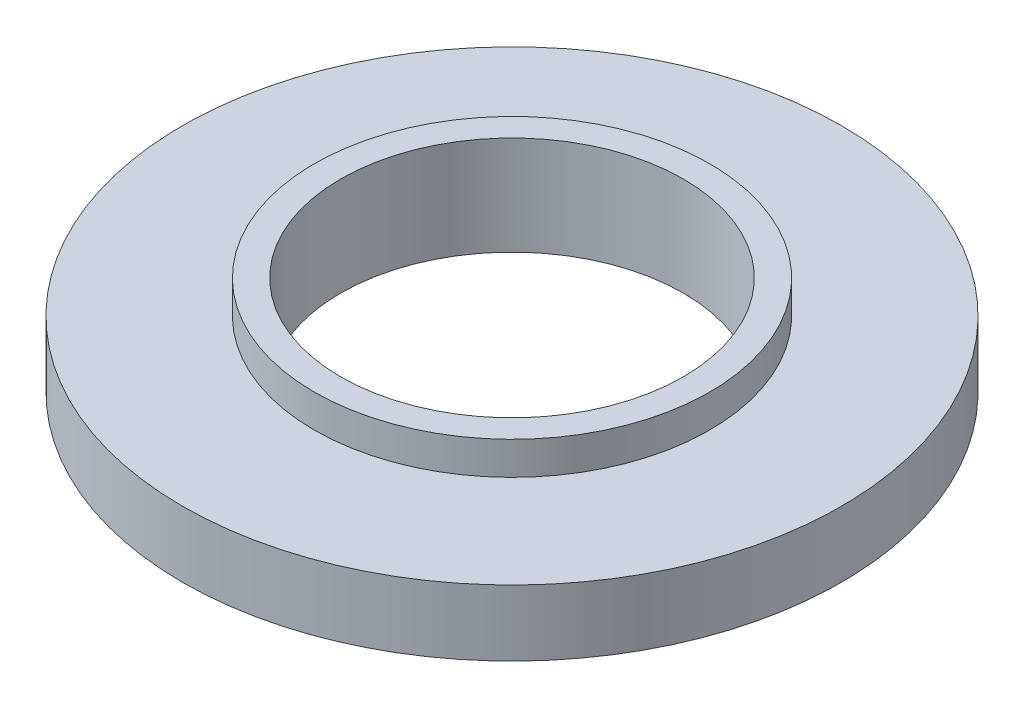
from build123d import *


with BuildPart() as part:
    # Sketch2 → Revolve1 (revolve)
    with BuildSketch(Plane.XY):
        Polygon((2.6, 0), (2.6, 1.5), (3, 1.5), (3, 1), (5, 1), (5, 0), align=None)
    revolve(axis=Axis((0, 8.660968661, 0), (0, -1, 0)))


solid = part.part
